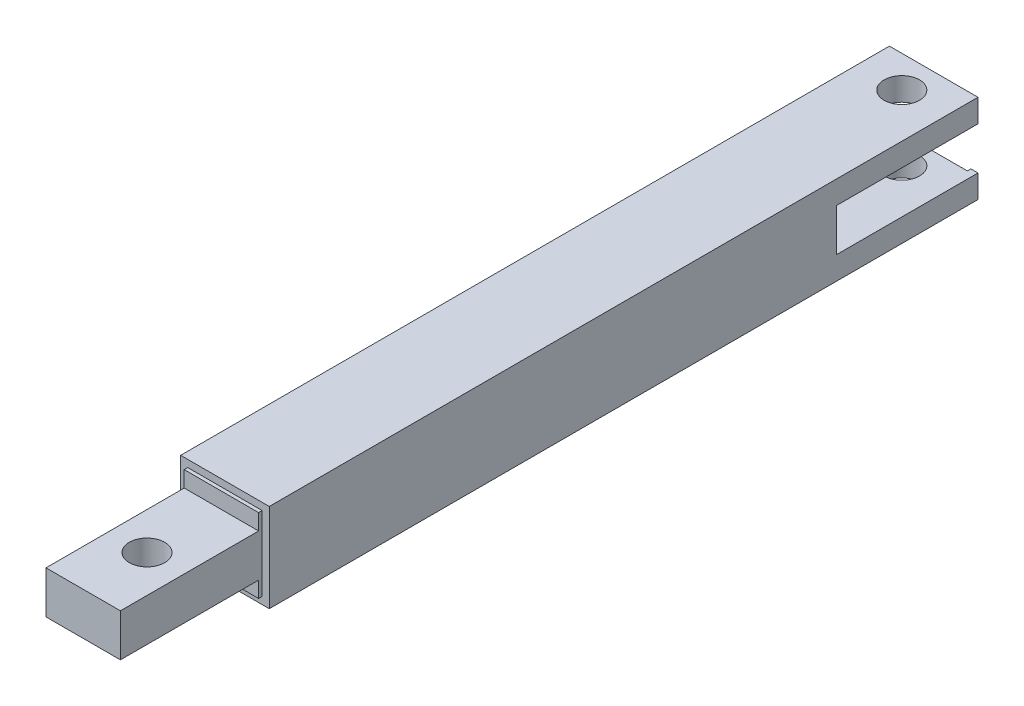
from build123d import *

# Parameters (mm, degrees)
SKETCH1_W                = 25
SKETCH1_H                = 25
SKETCH1_W_2              = 21
SKETCH1_H_2              = 21
BOSS_EXTRUDE1_DEPTH      = 200
SKETCH2_W                = 40
SKETCH2_H                = 12
CUT_EXTRUDE1_DEPTH       = 26
SKETCH3_R                = 5
CUT_EXTRUDE2_DEPTH       = 26
BOSS_EXTRUDE2_START      = -40
SKETCH5_W                = 21
SKETCH5_H                = 21
BOSS_EXTRUDE2_DEPTH      = 1
BOSS_EXTRUDE2_DEPTH_BACK = 199
SKETCH3_2_R              = 5
CUT_EXTRUDE4_DEPTH       = 239
SKETCH6_W                = 21
SKETCH6_H                = 12
CUT_EXTRUDE5_DEPTH       = 39
SKETCH8_W                = 21
SKETCH8_H                = 12
BOSS_EXTRUDE3_DEPTH      = 40
SKETCH9_R                = 5
CUT_EXTRUDE6_DEPTH       = 19.5


with BuildPart() as part:
    # Sketch1 → Boss-Extrude1 (new body)
    with BuildSketch(Plane.XY):
        Rectangle(SKETCH1_W, SKETCH1_H)
        Rectangle(SKETCH1_W_2, SKETCH1_H_2, mode=Mode.SUBTRACT)
    extrude(amount=BOSS_EXTRUDE1_DEPTH)

    # Sketch2 → Cut-Extrude1 (cut, through all)
    with BuildSketch(Plane(origin=(12.5, 0, 0), x_dir=(0, 0, -1), z_dir=(1, 0, 0))):
        with Locations((-20, 0)):
            Rectangle(SKETCH2_W, SKETCH2_H)
    extrude(amount=-CUT_EXTRUDE1_DEPTH, mode=Mode.SUBTRACT)

    # Sketch3 → Cut-Extrude2 (cut, through all)
    with BuildSketch(Plane(origin=(0, 12.5, 0), x_dir=(1, 0, 0), z_dir=(0, 1, 0))):
        with Locations((0, -9)):
            Circle(SKETCH3_R)
    extrude(amount=-CUT_EXTRUDE2_DEPTH, mode=Mode.SUBTRACT)

    # Sketch5 → Boss-Extrude2 (add, two sides)
    with BuildSketch(Plane.XY.offset(240).offset(BOSS_EXTRUDE2_START)) as boss_extrude2_sk:
        Rectangle(SKETCH5_W, SKETCH5_H)
    extrude(amount=BOSS_EXTRUDE2_DEPTH)
    extrude(boss_extrude2_sk.sketch, amount=-BOSS_EXTRUDE2_DEPTH_BACK)

    # Sketch3_2 → Cut-Extrude4 (cut)
    with BuildSketch(Plane(origin=(0, 12.5, 0), x_dir=(1, 0, 0), z_dir=(0, 1, 0))):
        with Locations((0, -9)):
            Circle(SKETCH3_2_R)
    extrude(amount=-CUT_EXTRUDE4_DEPTH, mode=Mode.SUBTRACT)

    # Sketch6 → Cut-Extrude5 (cut)
    with BuildSketch(Plane(origin=(0, 0, 1), x_dir=(-1, 0, 0), z_dir=(0, 0, -1))):
        Rectangle(SKETCH6_W, SKETCH6_H)
    extrude(amount=-CUT_EXTRUDE5_DEPTH, mode=Mode.SUBTRACT)

    # Sketch8 → Boss-Extrude3 (add)
    with BuildSketch(Plane.XY.offset(200)):
        Rectangle(SKETCH8_W, SKETCH8_H)
    extrude(amount=BOSS_EXTRUDE3_DEPTH)

    # Sketch9 → Cut-Extrude6 (cut, through all)
    with BuildSketch(Plane(origin=(0, 6, 0), x_dir=(1, 0, 0), z_dir=(0, 1, 0))):
        with Locations((0, -222)):
            Circle(SKETCH9_R)
    extrude(amount=-CUT_EXTRUDE6_DEPTH, mode=Mode.SUBTRACT)


solid = part.part
